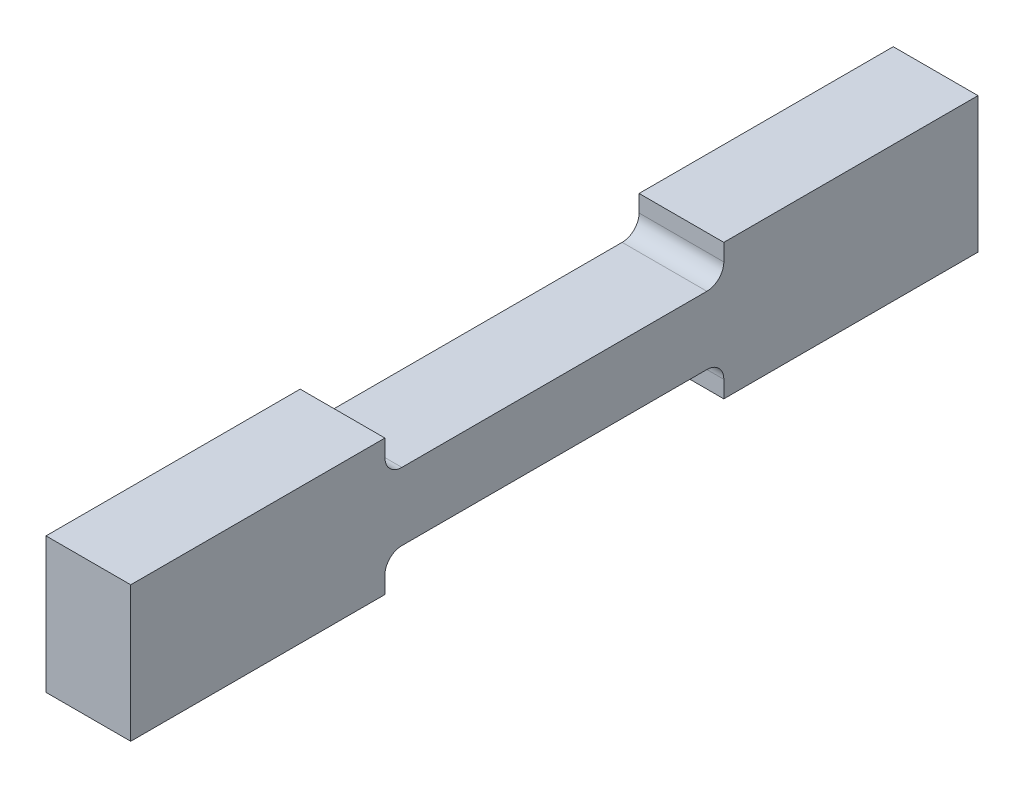
from build123d import *

# Parameters (mm, degrees)
EXTRUDE_1_DEPTH = 2.5
FILLET_1_R      = 0.5
FILLET_2_R      = 0.5
FILLET_3_R      = 0.5
FILLET_4_R      = 0.5


with BuildPart() as part:
    # 草图1 → 凸台-拉伸1 (new body)
    with BuildSketch(Plane(origin=(0, 0, 0), x_dir=(0, 0, -1), z_dir=(1, 0, 0))):
        Polygon((-5, 1), (5, 1), (5, 2), (12.5, 2), (12.5, -2), (5, -2), (5, -1), (-5, -1), (-5, -2), (-12.5, -2), (-12.5, 2), (-5, 2), align=None)
    extrude(amount=EXTRUDE_1_DEPTH)

    # 圆角1
    fillet_1_edges = [part.edges().sort_by_distance(p)[0] for p in [
        (1.25, 1, -5),
    ]]
    fillet(fillet_1_edges, radius=FILLET_1_R)

    # 圆角2
    fillet_2_edges = [part.edges().sort_by_distance(p)[0] for p in [
        (1.25, -1, -5),
    ]]
    fillet(fillet_2_edges, radius=FILLET_2_R)

    # 圆角3
    fillet_3_edges = [part.edges().sort_by_distance(p)[0] for p in [
        (1.25, 1, 5),
    ]]
    fillet(fillet_3_edges, radius=FILLET_3_R)

    # 圆角4
    fillet_4_edges = [part.edges().sort_by_distance(p)[0] for p in [
        (1.25, -1, 5),
    ]]
    fillet(fillet_4_edges, radius=FILLET_4_R)


solid = part.part
